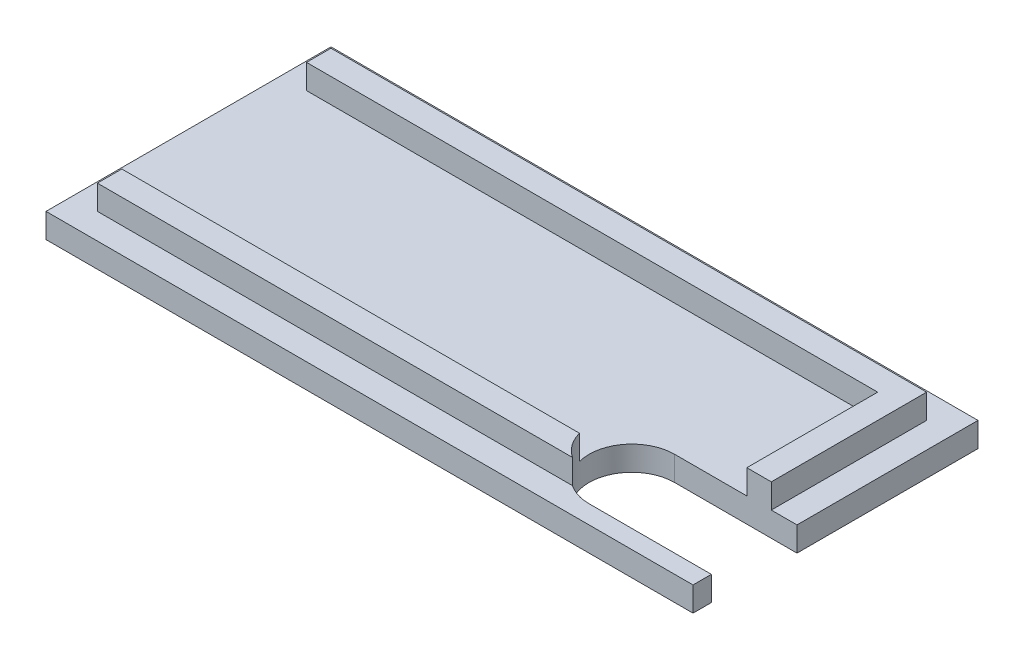
from build123d import *

# Parameters (mm, degrees)
SKETCH1_W           = 52.9
SKETCH1_H           = 23.3
BOSS_EXTRUDE1_DEPTH = 2
BOSS_EXTRUDE2_DEPTH = 2
CUT_EXTRUDE1_DEPTH  = 5


with BuildPart() as part:
    # Sketch1 → Boss-Extrude1 (new body)
    with BuildSketch(Plane(origin=(0, 0, 0), x_dir=(1, 0, 0), z_dir=(0, 1, 0))):
        with Locations((26.45, 11.65)):
            Rectangle(SKETCH1_W, SKETCH1_H)
    extrude(amount=BOSS_EXTRUDE1_DEPTH)

    # Sketch2 → Boss-Extrude2 (add)
    with BuildSketch(Plane(origin=(0, 2, 0), x_dir=(1, 0, 0), z_dir=(0, 1, 0))):
        Polygon((2.1, 21.2), (50.8, 21.2), (50.8, 2.1), (2.1, 2.1), (2.1, 4.1), (4.1, 4.1), (48.8, 4.1), (48.8, 19.2), (4.1, 19.2), (2.1, 19.2), align=None)
    extrude(amount=BOSS_EXTRUDE2_DEPTH)

    # Sketch3 → Cut-Extrude1 (cut, through all)
    with BuildSketch(Plane.XZ):
        with BuildLine():
            Line((42.9, -1.5), (53.235207038, -1.5))
            ThreePointArc((53.235207038, -1.5), (56.735207038, -5), (53.235207038, -8.5))
            Line((53.235207038, -8.5), (42.9, -8.5))
            ThreePointArc((42.9, -8.5), (39.4, -5), (42.9, -1.5))
        make_face()
    extrude(amount=-CUT_EXTRUDE1_DEPTH, mode=Mode.SUBTRACT)


solid = part.part
